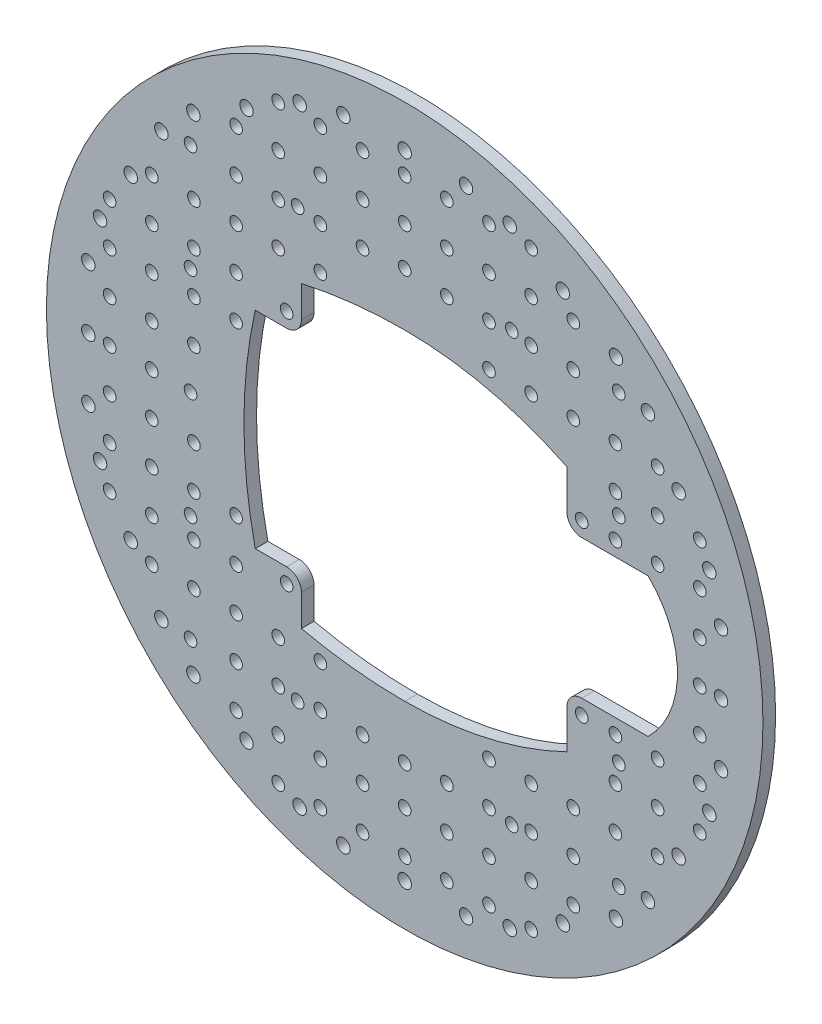
from build123d import *

# Parameters (mm, degrees)
MODEL_R         = 85
MODEL_R_2       = 1.6
MODEL_R_3       = 1.5
MODEL_R_4       = 1.500000001
EXTRUDE_1_DEPTH = 3


with BuildPart() as part:
    # Model → Бобышка-Вытянуть1 (new body)
    with BuildSketch(Plane.XY):
        Circle(MODEL_R)
        with Locations((37.525, 64.995206554)):
            Circle(MODEL_R_2, mode=Mode.SUBTRACT)
        with Locations((-50.125669625, -57.720206554)):
            Circle(MODEL_R_2, mode=Mode.SUBTRACT)
        with Locations((-57.720206554, 50.125669625)):
            Circle(MODEL_R_2, mode=Mode.SUBTRACT)
        with Locations((-24.924330375, 72.270206554)):
            Circle(MODEL_R_2, mode=Mode.SUBTRACT)
        with Locations((-75.05, 0)):
            Circle(MODEL_R_2, mode=Mode.SUBTRACT)
        with Locations((50.125669625, -57.720206554)):
            Circle(MODEL_R_2, mode=Mode.SUBTRACT)
        with Locations((-72.270206554, 24.924330375)):
            Circle(MODEL_R_2, mode=Mode.SUBTRACT)
        with Locations((64.995206554, -37.525)):
            Circle(MODEL_R_2, mode=Mode.SUBTRACT)
        with Locations((50.125669625, 57.720206554)):
            Circle(MODEL_R_2, mode=Mode.SUBTRACT)
        with Locations((37.525, -64.995206554)):
            Circle(MODEL_R_2, mode=Mode.SUBTRACT)
        with Locations((-14.55, 75.05)):
            Circle(MODEL_R_2, mode=Mode.SUBTRACT)
        with Locations((-72.270206554, -24.924330375)):
            Circle(MODEL_R_2, mode=Mode.SUBTRACT)
        with Locations((24.924330375, -72.270206554)):
            Circle(MODEL_R_2, mode=Mode.SUBTRACT)
        with Locations((14.55, -75.05)):
            Circle(MODEL_R_2, mode=Mode.SUBTRACT)
        with Locations((64.995206554, 37.525)):
            Circle(MODEL_R_2, mode=Mode.SUBTRACT)
        with Locations((-37.525, -64.995206554)):
            Circle(MODEL_R_2, mode=Mode.SUBTRACT)
        with Locations((-75.05, 14.55)):
            Circle(MODEL_R_2, mode=Mode.SUBTRACT)
        with Locations((72.270206554, 24.924330375)):
            Circle(MODEL_R_2, mode=Mode.SUBTRACT)
        with Locations((0, -75.05)):
            Circle(MODEL_R_2, mode=Mode.SUBTRACT)
        with Locations((-75.05, -14.55)):
            Circle(MODEL_R_2, mode=Mode.SUBTRACT)
        with Locations((-64.995206554, 37.525)):
            Circle(MODEL_R_2, mode=Mode.SUBTRACT)
        with Locations((-57.720206554, -50.125669625)):
            Circle(MODEL_R_2, mode=Mode.SUBTRACT)
        with Locations((57.720206554, 50.125669625)):
            Circle(MODEL_R_2, mode=Mode.SUBTRACT)
        with Locations((-14.55, -75.05)):
            Circle(MODEL_R_2, mode=Mode.SUBTRACT)
        with Locations((75.05, 14.55)):
            Circle(MODEL_R_2, mode=Mode.SUBTRACT)
        with Locations((24.924330375, 72.270206554)):
            Circle(MODEL_R_2, mode=Mode.SUBTRACT)
        with Locations((-50.125669625, 57.720206554)):
            Circle(MODEL_R_2, mode=Mode.SUBTRACT)
        with Locations((-24.924330375, -72.270206554)):
            Circle(MODEL_R_2, mode=Mode.SUBTRACT)
        with Locations((-64.995206554, -37.525)):
            Circle(MODEL_R_2, mode=Mode.SUBTRACT)
        with Locations((75.05, -14.55)):
            Circle(MODEL_R_2, mode=Mode.SUBTRACT)
        with Locations((14.55, 75.05)):
            Circle(MODEL_R_2, mode=Mode.SUBTRACT)
        with Locations((0, 75.05)):
            Circle(MODEL_R_2, mode=Mode.SUBTRACT)
        with Locations((57.720206554, -50.125669625)):
            Circle(MODEL_R_2, mode=Mode.SUBTRACT)
        with Locations((75.05, 0)):
            Circle(MODEL_R_2, mode=Mode.SUBTRACT)
        with Locations((72.270206554, -24.924330375)):
            Circle(MODEL_R_2, mode=Mode.SUBTRACT)
        with Locations((-37.525, 64.995206554)):
            Circle(MODEL_R_2, mode=Mode.SUBTRACT)
        with Locations((50.8, 25.4)):
            Circle(MODEL_R_3, mode=Mode.SUBTRACT)
        with Locations((0, 50.8)):
            Circle(MODEL_R_3, mode=Mode.SUBTRACT)
        with Locations((25.4, 50.8)):
            Circle(MODEL_R_3, mode=Mode.SUBTRACT)
        with Locations((50.8, 50.8)):
            Circle(MODEL_R_3, mode=Mode.SUBTRACT)
        with Locations((50.8, -25.4)):
            Circle(MODEL_R_3, mode=Mode.SUBTRACT)
        with Locations((0, -50.8)):
            Circle(MODEL_R_3, mode=Mode.SUBTRACT)
        with Locations((25.4, -50.8)):
            Circle(MODEL_R_3, mode=Mode.SUBTRACT)
        with Locations((50.8, -50.8)):
            Circle(MODEL_R_3, mode=Mode.SUBTRACT)
        with Locations((-50.8, 0)):
            Circle(MODEL_R_3, mode=Mode.SUBTRACT)
        with Locations((-50.8, 25.4)):
            Circle(MODEL_R_3, mode=Mode.SUBTRACT)
        with Locations((-25.4, 50.8)):
            Circle(MODEL_R_3, mode=Mode.SUBTRACT)
        with Locations((-50.8, 50.8)):
            Circle(MODEL_R_3, mode=Mode.SUBTRACT)
        with Locations((-50.8, -25.4)):
            Circle(MODEL_R_3, mode=Mode.SUBTRACT)
        with Locations((-25.4, -50.8)):
            Circle(MODEL_R_3, mode=Mode.SUBTRACT)
        with Locations((-50.8, -50.8)):
            Circle(MODEL_R_3, mode=Mode.SUBTRACT)
        with Locations((41.999999999, 20)):
            Circle(MODEL_R_4, mode=Mode.SUBTRACT)
        with Locations((-28.000000001, 28)):
            Circle(MODEL_R_4, mode=Mode.SUBTRACT)
        with Locations((42, -20)):
            Circle(MODEL_R_3, mode=Mode.SUBTRACT)
        with Locations((-28, -28)):
            Circle(MODEL_R_3, mode=Mode.SUBTRACT)
        with Locations((-10, 50)):
            Circle(MODEL_R_3, mode=Mode.SUBTRACT)
        with Locations((-10, 60)):
            Circle(MODEL_R_3, mode=Mode.SUBTRACT)
        with Locations((-10, 70)):
            Circle(MODEL_R_3, mode=Mode.SUBTRACT)
        with Locations((0, 60)):
            Circle(MODEL_R_3, mode=Mode.SUBTRACT)
        with Locations((0, 70)):
            Circle(MODEL_R_3, mode=Mode.SUBTRACT)
        with Locations((-20, 40)):
            Circle(MODEL_R_3, mode=Mode.SUBTRACT)
        with Locations((-20, 50)):
            Circle(MODEL_R_3, mode=Mode.SUBTRACT)
        with Locations((-20, 60)):
            Circle(MODEL_R_3, mode=Mode.SUBTRACT)
        with Locations((-20, 70)):
            Circle(MODEL_R_3, mode=Mode.SUBTRACT)
        with Locations((-30, 40)):
            Circle(MODEL_R_3, mode=Mode.SUBTRACT)
        with Locations((-30, 50)):
            Circle(MODEL_R_3, mode=Mode.SUBTRACT)
        with Locations((-30, 60)):
            Circle(MODEL_R_3, mode=Mode.SUBTRACT)
        with Locations((-30, 70)):
            Circle(MODEL_R_3, mode=Mode.SUBTRACT)
        with Locations((-40, 20)):
            Circle(MODEL_R_3, mode=Mode.SUBTRACT)
        with Locations((-40, 30)):
            Circle(MODEL_R_3, mode=Mode.SUBTRACT)
        with Locations((-40, 40)):
            Circle(MODEL_R_3, mode=Mode.SUBTRACT)
        with Locations((-40, 50)):
            Circle(MODEL_R_3, mode=Mode.SUBTRACT)
        with Locations((-40, 60)):
            Circle(MODEL_R_3, mode=Mode.SUBTRACT)
        with Locations((-50, 10)):
            Circle(MODEL_R_3, mode=Mode.SUBTRACT)
        with Locations((-50, 20)):
            Circle(MODEL_R_3, mode=Mode.SUBTRACT)
        with Locations((-50, 30)):
            Circle(MODEL_R_3, mode=Mode.SUBTRACT)
        with Locations((-50, 40)):
            Circle(MODEL_R_3, mode=Mode.SUBTRACT)
        with Locations((-60, 0)):
            Circle(MODEL_R_3, mode=Mode.SUBTRACT)
        with Locations((-60, 10)):
            Circle(MODEL_R_3, mode=Mode.SUBTRACT)
        with Locations((-60, 20)):
            Circle(MODEL_R_3, mode=Mode.SUBTRACT)
        with Locations((-60, 40)):
            Circle(MODEL_R_3, mode=Mode.SUBTRACT)
        with Locations((-70, 0)):
            Circle(MODEL_R_3, mode=Mode.SUBTRACT)
        with Locations((-70, 10)):
            Circle(MODEL_R_3, mode=Mode.SUBTRACT)
        with Locations((-70, 20)):
            Circle(MODEL_R_3, mode=Mode.SUBTRACT)
        with Locations((-70, 30)):
            Circle(MODEL_R_3, mode=Mode.SUBTRACT)
        with Locations((10, 50)):
            Circle(MODEL_R_3, mode=Mode.SUBTRACT)
        with Locations((10, 60)):
            Circle(MODEL_R_3, mode=Mode.SUBTRACT)
        with Locations((10, 70)):
            Circle(MODEL_R_3, mode=Mode.SUBTRACT)
        with Locations((20, 40)):
            Circle(MODEL_R_3, mode=Mode.SUBTRACT)
        with Locations((20, 50)):
            Circle(MODEL_R_3, mode=Mode.SUBTRACT)
        with Locations((20, 60)):
            Circle(MODEL_R_3, mode=Mode.SUBTRACT)
        with Locations((20, 70)):
            Circle(MODEL_R_3, mode=Mode.SUBTRACT)
        with Locations((30, 40)):
            Circle(MODEL_R_3, mode=Mode.SUBTRACT)
        with Locations((30, 50)):
            Circle(MODEL_R_3, mode=Mode.SUBTRACT)
        with Locations((30, 60)):
            Circle(MODEL_R_3, mode=Mode.SUBTRACT)
        with Locations((30, 70)):
            Circle(MODEL_R_3, mode=Mode.SUBTRACT)
        with Locations((40, 40)):
            Circle(MODEL_R_3, mode=Mode.SUBTRACT)
        with Locations((40, 50)):
            Circle(MODEL_R_3, mode=Mode.SUBTRACT)
        with Locations((40, 60)):
            Circle(MODEL_R_3, mode=Mode.SUBTRACT)
        with Locations((50, 20)):
            Circle(MODEL_R_3, mode=Mode.SUBTRACT)
        with Locations((50, 30)):
            Circle(MODEL_R_3, mode=Mode.SUBTRACT)
        with Locations((50, 40)):
            Circle(MODEL_R_3, mode=Mode.SUBTRACT)
        with Locations((60, 20)):
            Circle(MODEL_R_3, mode=Mode.SUBTRACT)
        with Locations((60, 30)):
            Circle(MODEL_R_3, mode=Mode.SUBTRACT)
        with Locations((60, 40)):
            Circle(MODEL_R_3, mode=Mode.SUBTRACT)
        with Locations((70, 10)):
            Circle(MODEL_R_3, mode=Mode.SUBTRACT)
        with Locations((70, 20)):
            Circle(MODEL_R_3, mode=Mode.SUBTRACT)
        with Locations((70, 30)):
            Circle(MODEL_R_3, mode=Mode.SUBTRACT)
        with Locations((70, 0)):
            Circle(MODEL_R_3, mode=Mode.SUBTRACT)
        with Locations((-10, -50)):
            Circle(MODEL_R_3, mode=Mode.SUBTRACT)
        with Locations((-10, -60)):
            Circle(MODEL_R_3, mode=Mode.SUBTRACT)
        with Locations((-10, -70)):
            Circle(MODEL_R_3, mode=Mode.SUBTRACT)
        with Locations((0, -60)):
            Circle(MODEL_R_3, mode=Mode.SUBTRACT)
        with Locations((0, -70)):
            Circle(MODEL_R_3, mode=Mode.SUBTRACT)
        with Locations((-20, -40)):
            Circle(MODEL_R_3, mode=Mode.SUBTRACT)
        with Locations((-20, -50)):
            Circle(MODEL_R_3, mode=Mode.SUBTRACT)
        with Locations((-20, -60)):
            Circle(MODEL_R_3, mode=Mode.SUBTRACT)
        with Locations((-20, -70)):
            Circle(MODEL_R_3, mode=Mode.SUBTRACT)
        with Locations((-30, -40)):
            Circle(MODEL_R_3, mode=Mode.SUBTRACT)
        with Locations((-30, -50)):
            Circle(MODEL_R_3, mode=Mode.SUBTRACT)
        with Locations((-30, -60)):
            Circle(MODEL_R_3, mode=Mode.SUBTRACT)
        with Locations((-30, -70)):
            Circle(MODEL_R_3, mode=Mode.SUBTRACT)
        with Locations((-40, -20)):
            Circle(MODEL_R_3, mode=Mode.SUBTRACT)
        with Locations((-40, -30)):
            Circle(MODEL_R_3, mode=Mode.SUBTRACT)
        with Locations((-40, -40)):
            Circle(MODEL_R_3, mode=Mode.SUBTRACT)
        with Locations((-40, -50)):
            Circle(MODEL_R_3, mode=Mode.SUBTRACT)
        with Locations((-40, -60)):
            Circle(MODEL_R_3, mode=Mode.SUBTRACT)
        with Locations((-50, -10)):
            Circle(MODEL_R_3, mode=Mode.SUBTRACT)
        with Locations((-50, -20)):
            Circle(MODEL_R_3, mode=Mode.SUBTRACT)
        with Locations((-50, -30)):
            Circle(MODEL_R_3, mode=Mode.SUBTRACT)
        with Locations((-50, -40)):
            Circle(MODEL_R_3, mode=Mode.SUBTRACT)
        with Locations((-60, -10)):
            Circle(MODEL_R_3, mode=Mode.SUBTRACT)
        with Locations((-60, -20)):
            Circle(MODEL_R_3, mode=Mode.SUBTRACT)
        with Locations((-60, -40)):
            Circle(MODEL_R_3, mode=Mode.SUBTRACT)
        with Locations((-70, -10)):
            Circle(MODEL_R_3, mode=Mode.SUBTRACT)
        with Locations((-70, -20)):
            Circle(MODEL_R_3, mode=Mode.SUBTRACT)
        with Locations((-70, -30)):
            Circle(MODEL_R_3, mode=Mode.SUBTRACT)
        with Locations((10, -50)):
            Circle(MODEL_R_3, mode=Mode.SUBTRACT)
        with Locations((10, -60)):
            Circle(MODEL_R_3, mode=Mode.SUBTRACT)
        with Locations((10, -70)):
            Circle(MODEL_R_3, mode=Mode.SUBTRACT)
        with Locations((20, -40)):
            Circle(MODEL_R_3, mode=Mode.SUBTRACT)
        with Locations((20, -50)):
            Circle(MODEL_R_3, mode=Mode.SUBTRACT)
        with Locations((20, -60)):
            Circle(MODEL_R_3, mode=Mode.SUBTRACT)
        with Locations((20, -70)):
            Circle(MODEL_R_3, mode=Mode.SUBTRACT)
        with Locations((30, -40)):
            Circle(MODEL_R_3, mode=Mode.SUBTRACT)
        with Locations((30, -50)):
            Circle(MODEL_R_3, mode=Mode.SUBTRACT)
        with Locations((30, -60)):
            Circle(MODEL_R_3, mode=Mode.SUBTRACT)
        with Locations((30, -70)):
            Circle(MODEL_R_3, mode=Mode.SUBTRACT)
        with Locations((40, -40)):
            Circle(MODEL_R_3, mode=Mode.SUBTRACT)
        with Locations((40, -50)):
            Circle(MODEL_R_3, mode=Mode.SUBTRACT)
        with Locations((40, -60)):
            Circle(MODEL_R_3, mode=Mode.SUBTRACT)
        with Locations((50, -20)):
            Circle(MODEL_R_3, mode=Mode.SUBTRACT)
        with Locations((50, -30)):
            Circle(MODEL_R_3, mode=Mode.SUBTRACT)
        with Locations((50, -40)):
            Circle(MODEL_R_3, mode=Mode.SUBTRACT)
        with Locations((60, -20)):
            Circle(MODEL_R_3, mode=Mode.SUBTRACT)
        with Locations((60, -30)):
            Circle(MODEL_R_3, mode=Mode.SUBTRACT)
        with Locations((60, -40)):
            Circle(MODEL_R_3, mode=Mode.SUBTRACT)
        with Locations((70, -10)):
            Circle(MODEL_R_3, mode=Mode.SUBTRACT)
        with Locations((70, -20)):
            Circle(MODEL_R_3, mode=Mode.SUBTRACT)
        with Locations((70, -30)):
            Circle(MODEL_R_3, mode=Mode.SUBTRACT)
        with Locations((-60, 30)):
            Circle(MODEL_R_3, mode=Mode.SUBTRACT)
        with Locations((-60, -30)):
            Circle(MODEL_R_3, mode=Mode.SUBTRACT)
        with BuildLine():
            Line((38.499999999, 20), (38.499999999, 29.277017301))
            ThreePointArc((38.499999999, 29.277017301), (19.753534985, 35.895906717), (-1e-09, 38.140344993))
            ThreePointArc((-1e-09, 38.140344993), (-12.323772559, 37.465109631), (-24.500000001, 35.447487731))
            Line((-24.500000001, 35.447487731), (-24.500000001, 28))
            ThreePointArc((-24.500000001, 28), (-25.525126266, 25.525126266), (-28.000000001, 24.5))
            Line((-28.000000001, 24.5), (-35.447487732, 24.5))
            ThreePointArc((-35.447487732, 24.5), (-37.465109632, 12.323772559), (-38.140344994, 1e-09))
            ThreePointArc((-38.140344994, 1e-09), (-37.465109632, -12.323772557), (-35.447487732, -24.5))
            Line((-35.447487732, -24.5), (-28, -24.5))
            ThreePointArc((-28, -24.5), (-25.525126266, -25.525126266), (-24.5, -28))
            Line((-24.5, -28), (-24.5, -35.447487731))
            ThreePointArc((-24.5, -35.447487731), (-12.323772558, -37.465109631), (0, -38.140344993))
            ThreePointArc((0, -38.140344993), (19.753534986, -35.895906717), (38.5, -29.277017301))
            Line((38.5, -29.277017301), (38.5, -20))
            ThreePointArc((38.5, -20), (39.525126266, -17.525126266), (42, -16.5))
            Line((42, -16.5), (57.742586409, -16.5))
            ThreePointArc((57.742586409, -16.5), (62.903342553, -8.957157242), (64.71916605, 1e-09))
            ThreePointArc((64.71916605, 1e-09), (62.903342553, 8.957157243), (57.742586408, 16.5))
            Line((57.742586408, 16.5), (41.999999999, 16.5))
            ThreePointArc((41.999999999, 16.5), (39.525126265, 17.525126266), (38.499999999, 20))
        make_face(mode=Mode.SUBTRACT)
    extrude(amount=EXTRUDE_1_DEPTH)


solid = part.part
